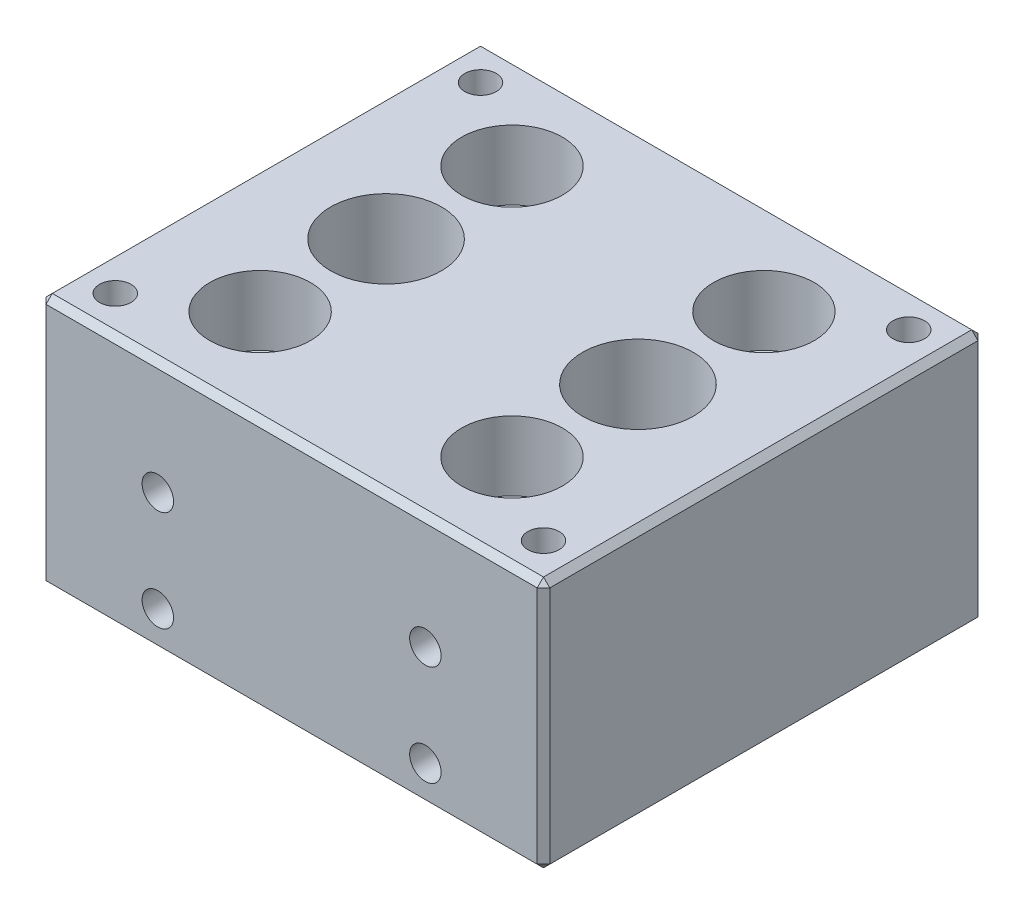
from build123d import *

# Parameters (mm, degrees)
SKETCH1_W                       = 40
SKETCH1_H                       = 35
BOSS_EXTRUDE1_DEPTH             = 20
TAP_DRILL_FOR_M3X0_5_TAP1_D     = 2.5
TAP_DRILL_FOR_M3X0_5_TAP1_DEPTH = 4
F_8_4_8_4_DIAMETER_HOLE2_D      = 8.4
F_8_4_8_4_DIAMETER_HOLE2_DEPTH  = 15
F_8_4_8_4_DIAMETER_HOLE2_TIP    = 2.5236146
F_8_4_8_4_DIAMETER_HOLE1_D      = 8.4
F_8_4_8_4_DIAMETER_HOLE1_DEPTH  = 35
F_8_4_8_4_DIAMETER_HOLE1_TIP    = 2.5236146
F_7_0_7_DIAMETER_HOLE1_D        = 7
F_7_0_7_DIAMETER_HOLE1_DEPTH    = 15
F_7_0_7_DIAMETER_HOLE1_TIP      = 2.103012167
F_8_0_8_DIAMETER_HOLE1_D        = 8
F_8_0_8_DIAMETER_HOLE1_DEPTH    = 5.5
TAP_DRILL_FOR_M3X0_5_TAP2_D     = 2.5
TAP_DRILL_FOR_M3X0_5_TAP2_DEPTH = 5.5
CHAMFER1_SIZE                   = 0.5
G1_8_TAPPED_HOLE1_D             = 8.8
G1_8_TAPPED_HOLE1_DEPTH         = 10


with BuildPart() as part:
    # Sketch1 → Boss-Extrude1 (new body)
    with BuildSketch(Plane(origin=(0, 0, 0), x_dir=(1, 0, 0), z_dir=(0, 1, 0))):
        Rectangle(SKETCH1_W, SKETCH1_H)
    extrude(amount=BOSS_EXTRUDE1_DEPTH)

    # Tap Drill for M3x0.5 Tap1
    with Locations(Plane(origin=(0, 20, 0), x_dir=(1, 0, 0), z_dir=(0, 1, 0))):
        with Locations((-17, 14.5), (17, 14.5), (17, -14.5), (-17, -14.5)):
            Hole(TAP_DRILL_FOR_M3X0_5_TAP1_D / 2, depth=TAP_DRILL_FOR_M3X0_5_TAP1_DEPTH)

    # Ø8.4 (8.4) Diameter Hole2
    with Locations(Plane(origin=(0, 20, 0), x_dir=(1, 0, 0), z_dir=(0, 1, 0))):
        with Locations((-10, 0), (10, 0)):
            Hole(F_8_4_8_4_DIAMETER_HOLE2_D / 2, depth=F_8_4_8_4_DIAMETER_HOLE2_DEPTH)
            with Locations((0, 0, -(F_8_4_8_4_DIAMETER_HOLE2_DEPTH + F_8_4_8_4_DIAMETER_HOLE2_TIP / 2))):  # 118° drill point
                Cone(0, F_8_4_8_4_DIAMETER_HOLE2_D / 2, F_8_4_8_4_DIAMETER_HOLE2_TIP, mode=Mode.SUBTRACT)

    # Ø8.4 (8.4) Diameter Hole1
    with Locations(Plane.ZY.offset(20)):
        with Locations((0, 5)):
            Hole(F_8_4_8_4_DIAMETER_HOLE1_D / 2, depth=F_8_4_8_4_DIAMETER_HOLE1_DEPTH)
            with Locations((0, 0, -(F_8_4_8_4_DIAMETER_HOLE1_DEPTH + F_8_4_8_4_DIAMETER_HOLE1_TIP / 2))):  # 118° drill point
                Cone(0, F_8_4_8_4_DIAMETER_HOLE1_D / 2, F_8_4_8_4_DIAMETER_HOLE1_TIP, mode=Mode.SUBTRACT)

    # Ø7.0 (7) Diameter Hole1
    with Locations(Plane(origin=(0, 0, 0), x_dir=(-1, 0, 0), z_dir=(0, -1, 0))):
        with Locations((10, -10), (-10, -10), (-10, 10), (10, 10)):
            Hole(F_7_0_7_DIAMETER_HOLE1_D / 2, depth=F_7_0_7_DIAMETER_HOLE1_DEPTH)
            with Locations((0, 0, -(F_7_0_7_DIAMETER_HOLE1_DEPTH + F_7_0_7_DIAMETER_HOLE1_TIP / 2))):  # 118° drill point
                Cone(0, F_7_0_7_DIAMETER_HOLE1_D / 2, F_7_0_7_DIAMETER_HOLE1_TIP, mode=Mode.SUBTRACT)

    # Ø8.0 (8) Diameter Hole1
    with Locations(Plane(origin=(0, 20, 0), x_dir=(1, 0, 0), z_dir=(0, 1, 0))):
        with Locations((-10, 10), (10, 10), (10, -10), (-10, -10)):
            Hole(F_8_0_8_DIAMETER_HOLE1_D / 2, depth=F_8_0_8_DIAMETER_HOLE1_DEPTH)

    # Tap Drill for M3x0.5 Tap2
    with Locations(Plane.XY.offset(17.5)):
        with Locations((-10.622143035, 11), (-10.622143035, 3), (10.622143035, 3), (10.622143035, 11)):
            tap_drill_for_m3x0_5_tap2 = Hole(TAP_DRILL_FOR_M3X0_5_TAP2_D / 2, depth=TAP_DRILL_FOR_M3X0_5_TAP2_DEPTH)

    # Mirror1: Tap Drill for M3x0.5 Tap2 across plane
    add(tap_drill_for_m3x0_5_tap2.mirror(Plane.XY), mode=Mode.SUBTRACT)

    # Chamfer1
    chamfer1_edges = [part.edges().sort_by_distance(p)[0] for p in [
        (-20, 20, 0),
        (0, 20, 17.5),
        (20, 20, 0),
        (0, 0, 17.5),
        (-20, 0, 0),
        (0, 0, -17.5),
        (20, 0, 0),
        (0, 20, -17.5),
        (20, 10, 17.5),
        (-20, 10, 17.5),
        (-20, 10, -17.5),
        (20, 10, -17.5),
    ]]
    chamfer(chamfer1_edges, length=CHAMFER1_SIZE)

    # G1/8 Tapped Hole1
    with Locations(Plane(origin=(0, 20, 0), x_dir=(1, 0, 0), z_dir=(0, 1, 0))):
        with Locations((-10, 0), (10, 0)):
            Hole(G1_8_TAPPED_HOLE1_D / 2, depth=G1_8_TAPPED_HOLE1_DEPTH)


solid = part.part
